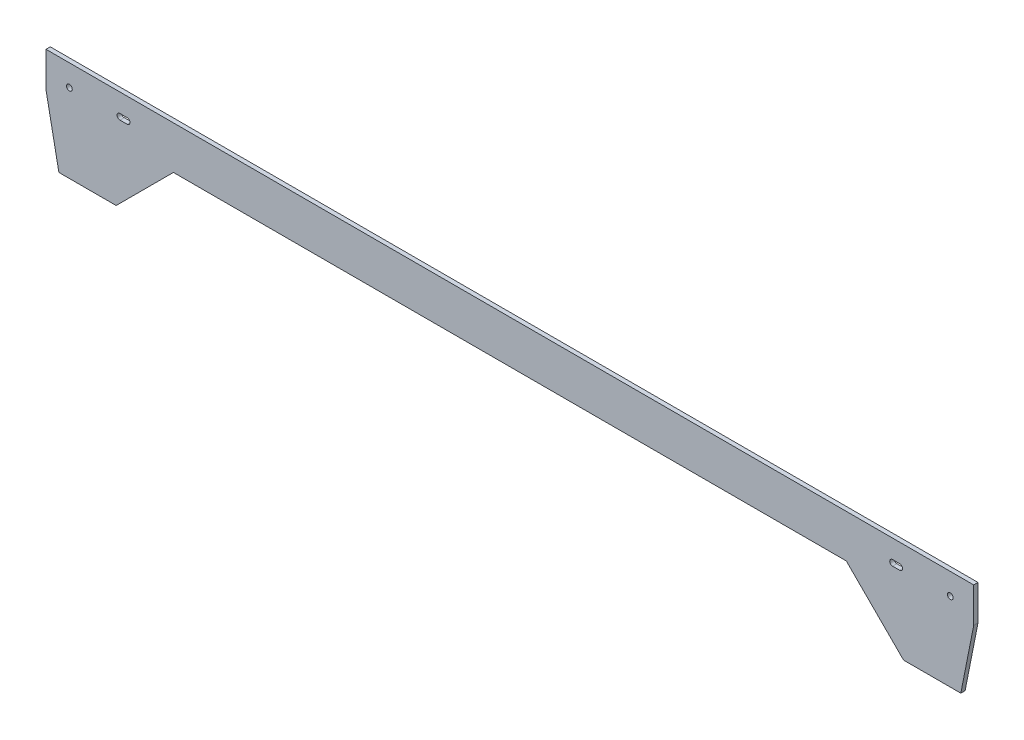
from build123d import *

# Parameters (mm, degrees)
CROQUIS1_R              = 4
SALIENTE_EXTRUIR1_DEPTH = 6


with BuildPart() as part:
    # Croquis1 → Saliente-Extruir1 (new body)
    with BuildSketch(Plane.XY):
        Polygon((-560, 30), (-600, 30), (-648, 30), (-648, -19), (-630, -110), (-600, -110), (-550, -110), (-470, -30), (470, -30), (550, -110), (600, -110), (630, -110), (648, -19), (648, 30), (600, 30), (560, 30), align=None)
        with Locations((-615.3, 0)):
            Circle(CROQUIS1_R, mode=Mode.SUBTRACT)
        with BuildLine():
            ThreePointArc((-544.7, -4), (-548.7, 0), (-544.7, 4))
            Line((-544.7, 4), (-534.7, 4))
            ThreePointArc((-534.7, 4), (-530.7, 0), (-534.7, -4))
            Line((-534.7, -4), (-544.7, -4))
        make_face(mode=Mode.SUBTRACT)
        with BuildLine():
            ThreePointArc((544.7, 4), (548.7, 0), (544.7, -4))
            Line((544.7, -4), (534.7, -4))
            ThreePointArc((534.7, -4), (530.7, 0), (534.7, 4))
            Line((534.7, 4), (544.7, 4))
        make_face(mode=Mode.SUBTRACT)
        with Locations((615.3, 0)):
            Circle(CROQUIS1_R, mode=Mode.SUBTRACT)
    extrude(amount=SALIENTE_EXTRUIR1_DEPTH)


solid = part.part
